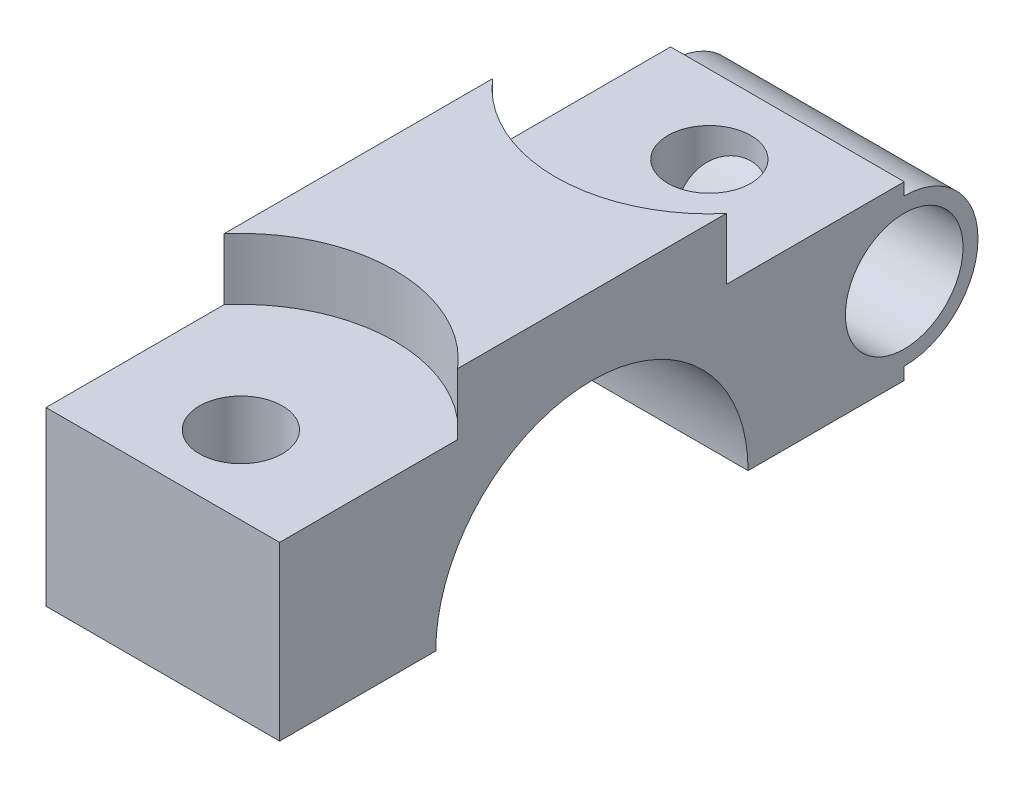
from build123d import *

# Parameters (mm, degrees)
BOSS_EXTRUDE1_DEPTH                      = 9.5
CBORE_FOR_M12_HEX_HEAD_BOLT3_D           = 6.75
CBORE_FOR_M12_HEX_HEAD_BOLT3_CBORE_D     = 25
CBORE_FOR_M12_HEX_HEAD_BOLT3_CBORE_DEPTH = 5
SKETCH6_R                                = 4.785
CUT_EXTRUDE1_DEPTH                       = 19
SKETCH6_3_R                              = 6
SKETCH6_3_R_2                            = 4.785
BOSS_EXTRUDE2_DEPTH                      = 19


with BuildPart() as part:
    # Sketch1 → Boss-Extrude1 (new, symmetric)
    with BuildSketch(Plane(origin=(0, 0, 0), x_dir=(0, 0, -1), z_dir=(1, 0, 0))):
        with BuildLine():
            Line((12.7, 0), (25.4, 0))
            Line((25.4, 0), (25.4, 19))
            Line((25.4, 19), (-25.4, 19))
            Line((-25.4, 19), (-25.4, 0))
            Line((-25.4, 0), (-12.7, 0))
            ThreePointArc((-12.7, 0), (0, 12.7), (12.7, 0))
        make_face()
    extrude(amount=BOSS_EXTRUDE1_DEPTH, both=True)

    # CBORE for M12 Hex Head Bolt3 (through all)
    with Locations(Plane(origin=(0, 19, 0), x_dir=(1, 0, 0), z_dir=(0, 1, 0))):
        with Locations((0, 19.05), (0, -19.05)):
            CounterBoreHole(CBORE_FOR_M12_HEX_HEAD_BOLT3_D / 2, CBORE_FOR_M12_HEX_HEAD_BOLT3_CBORE_D / 2, CBORE_FOR_M12_HEX_HEAD_BOLT3_CBORE_DEPTH)

    # Sketch6 → Cut-Extrude1 (cut)
    with BuildSketch(Plane(origin=(9.5, 0, 0), x_dir=(0, 0, -1), z_dir=(1, 0, 0))):
        with Locations((25.4, 7)):
            Circle(SKETCH6_R)
    extrude(amount=-CUT_EXTRUDE1_DEPTH, mode=Mode.SUBTRACT)

    # Sketch6_3 → Boss-Extrude2 (add)
    with BuildSketch(Plane(origin=(9.5, 0, 0), x_dir=(0, 0, -1), z_dir=(1, 0, 0))):
        with Locations((25.4, 7)):
            Circle(SKETCH6_3_R)
        with Locations((25.4, 7)):
            Circle(SKETCH6_3_R_2, mode=Mode.SUBTRACT)
    extrude(amount=-BOSS_EXTRUDE2_DEPTH)


solid = part.part
